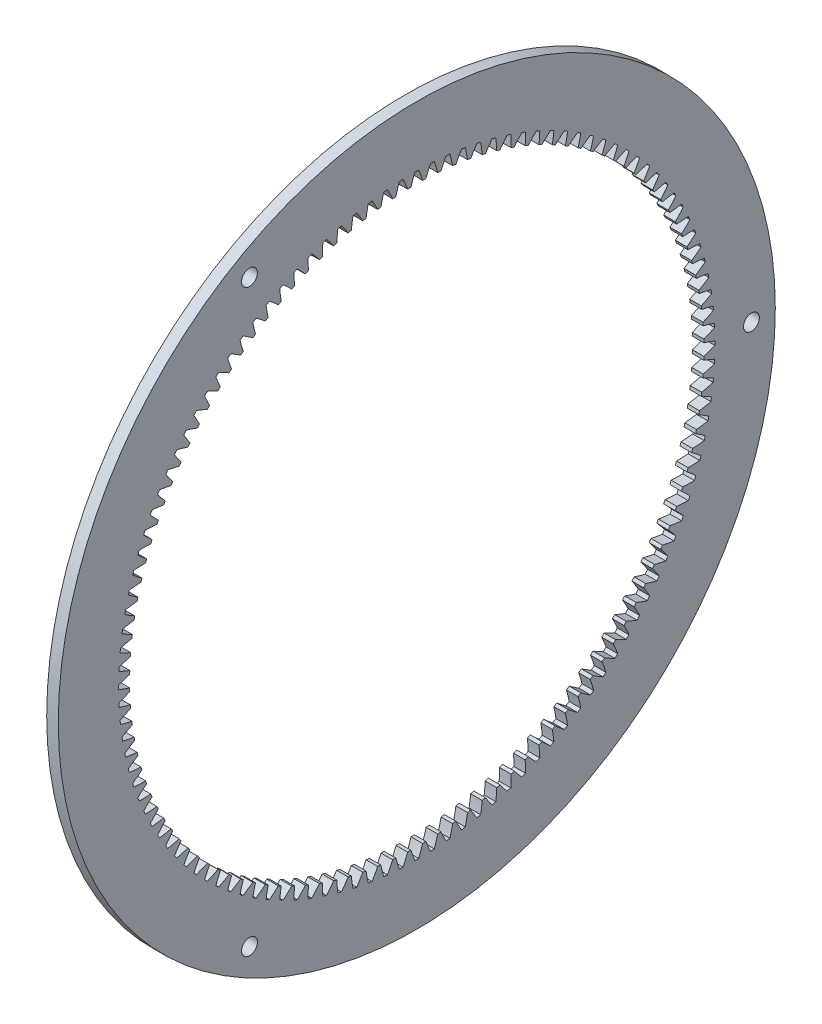
from build123d import *

# Parameters (mm, degrees)
BASPROSKE_W        = 4.7625
BASPROSKE_H        = 29.32
TOOTHCUT_DEPTH     = 209.396368026
TEETHCUTS_COUNT    = 120
TEETHCUTS_ANGLE    = 357
SKETCH1_R          = 3.2639
CUT_EXTRUDE1_DEPTH = 209.396368026


with BuildPart() as part:
    # BasProSke → Base-Revolve (revolve)
    with BuildSketch(Plane(origin=(0, 0, 0), x_dir=(1, 0, 0), z_dir=(0, 1, 0))):
        with Locations((2.38125, 132.66)):
            Rectangle(BASPROSKE_W, BASPROSKE_H)
    revolve(axis=Axis((-10, 0, 0), (1, 0, 0)))

    # TooCutSke → ToothCut (cut, through all)
    with BuildSketch(Plane(origin=(0, 0, 0), x_dir=(0, 0, -1), z_dir=(1, 0, 0))):
        with BuildLine():
            ThreePointArc((2.41396766, 117.949900404), (1.648624524, 120.240498651), (0.791720585, 122.498441539))
            ThreePointArc((0.791720585, 122.498441539), (0, 122.501), (-0.791720585, 122.498441539))
            ThreePointArc((-0.791720585, 122.498441539), (-1.648624524, 120.240498651), (-2.41396766, 117.949900404))
            ThreePointArc((-2.41396766, 117.949900404), (0, 117.9746), (2.41396766, 117.949900404))
        make_face()
    toothcut = extrude(amount=TOOTHCUT_DEPTH, mode=Mode.SUBTRACT)

    # TeethCuts: ToothCut ×120 about axis
    teethcuts_axis = Axis((-10, 0, 0), (1, 0, 0))
    for i in range(1, TEETHCUTS_COUNT):
        add(toothcut.rotate(teethcuts_axis, i * TEETHCUTS_ANGLE / (TEETHCUTS_COUNT - 1)), mode=Mode.SUBTRACT)

    # Sketch1 → Cut-Extrude1 (cut, through all)
    with BuildSketch(Plane(origin=(4.7625, 0, 0), x_dir=(0, 0, -1), z_dir=(1, 0, 0))):
        with Locations((-68.750000014, 119.078493045)):
            Circle(SKETCH1_R)
        with Locations((137.500000028, 0)):
            Circle(SKETCH1_R)
        with Locations((-68.750000014, -119.078493045)):
            Circle(SKETCH1_R)
    extrude(amount=-CUT_EXTRUDE1_DEPTH, mode=Mode.SUBTRACT)


solid = part.part
